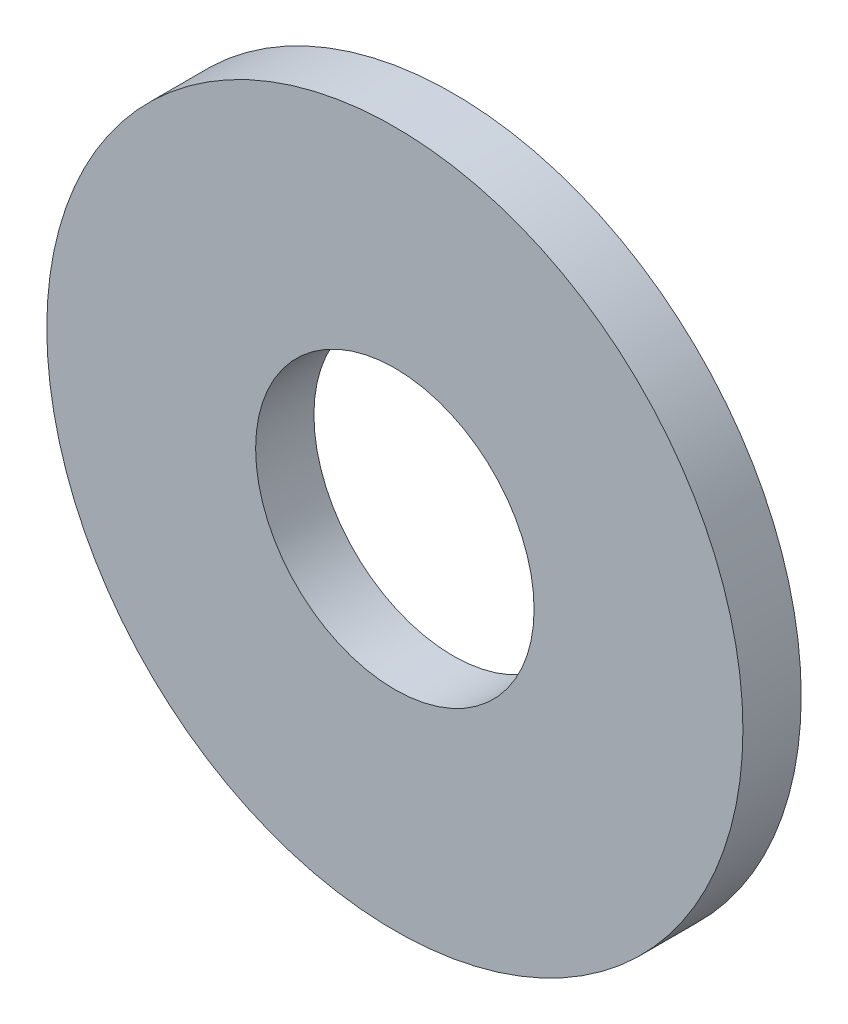
from build123d import *

# Parameters (mm, degrees)
SKETCH1_R      = 4
SKETCH1_R_2    = 1.6
EXTRUDE1_DEPTH = 0.67


with BuildPart() as part:
    # Sketch1 → Extrude1 (new body)
    with BuildSketch(Plane.XY):
        Circle(SKETCH1_R)
        Circle(SKETCH1_R_2, mode=Mode.SUBTRACT)
    extrude(amount=-EXTRUDE1_DEPTH)


solid = part.part
